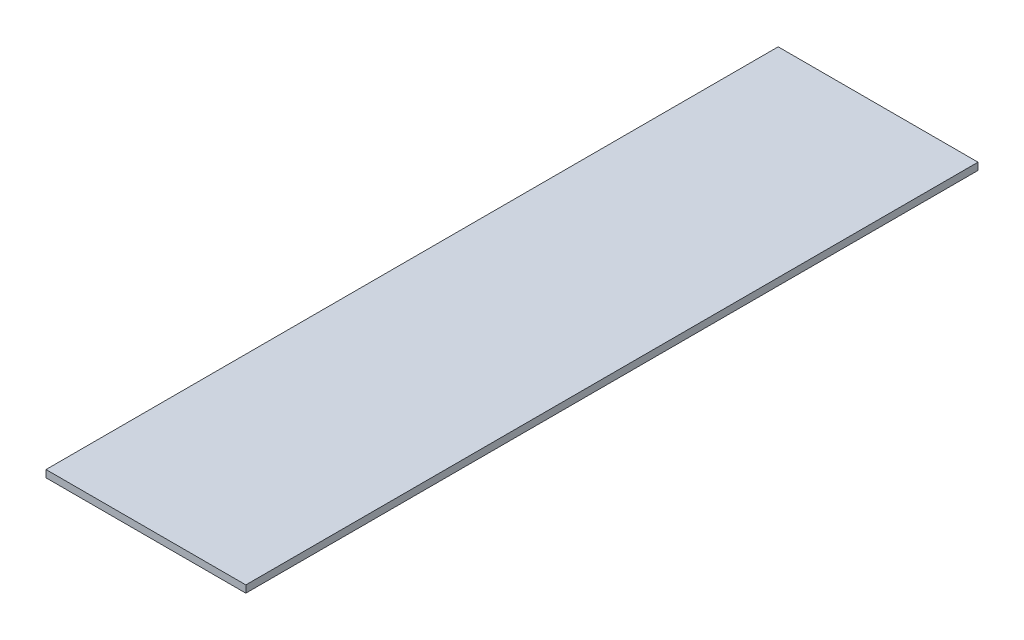
from build123d import *

# Parameters (mm, degrees)
SKETCH1_W           = 25
SKETCH1_H           = 91.6
BOSS_EXTRUDE1_DEPTH = 0.9


with BuildPart() as part:
    # Sketch1 → Boss-Extrude1 (new body)
    with BuildSketch(Plane(origin=(0, 0, 0), x_dir=(1, 0, 0), z_dir=(0, 1, 0))):
        with Locations((0, 154.929625)):
            Rectangle(SKETCH1_W, SKETCH1_H)
    extrude(amount=BOSS_EXTRUDE1_DEPTH)


solid = part.part
